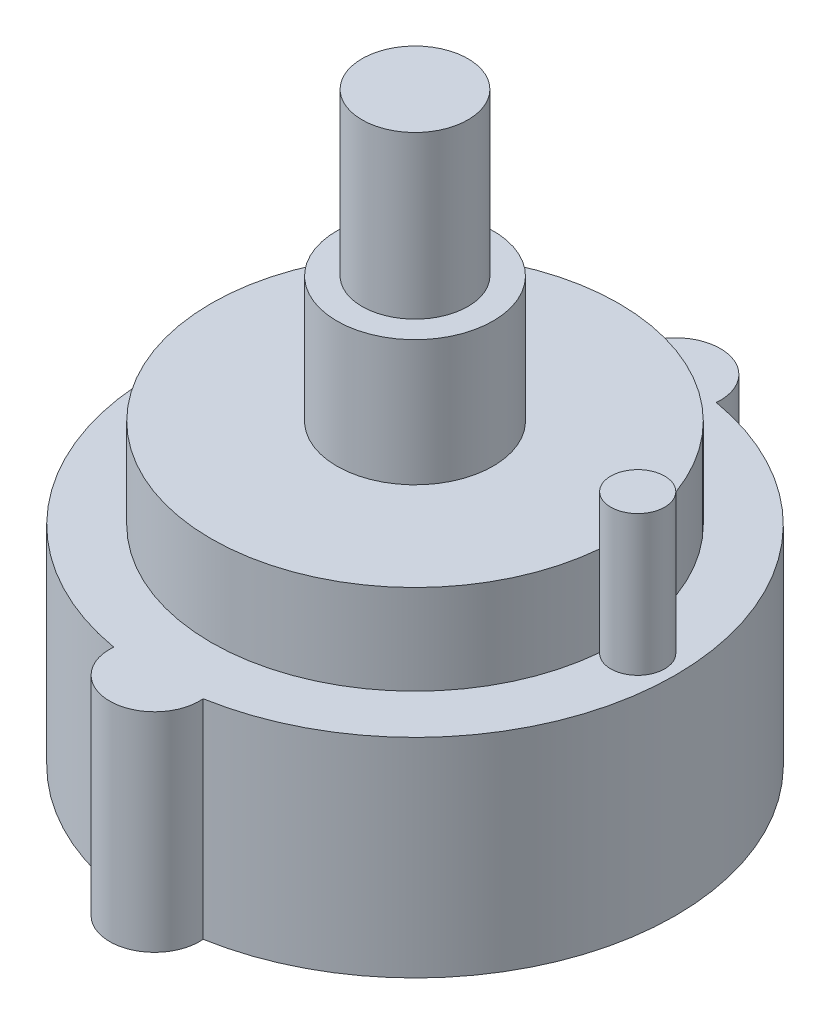
from build123d import *

# Parameters (mm, degrees)
SKETCH1_R                = 14.5
BOSS_EXTRUDE1_DEPTH      = 11.6
SKETCH2_R                = 11.35
BOSS_EXTRUDE2_DEPTH      = 5
SKETCH3_R                = 4.35
BOSS_EXTRUDE3_DEPTH      = 7
SKETCH4_R                = 2.95
BOSS_EXTRUDE4_DEPTH      = 9
SKETCH5_R                = 2.5
BOSS_EXTRUDE5_DEPTH      = 11.6
SKETCH6_R                = 1.5
BOSS_EXTRUDE6_DEPTH      = 2.8
BOSS_EXTRUDE6_DEPTH_BACK = 16.6


with BuildPart() as part:
    # Sketch1 → Boss-Extrude1 (new body)
    with BuildSketch(Plane(origin=(0, 0, 0), x_dir=(1, 0, 0), z_dir=(0, 1, 0))):
        Circle(SKETCH1_R)
    extrude(amount=BOSS_EXTRUDE1_DEPTH)

    # Sketch2 → Boss-Extrude2 (add)
    with BuildSketch(Plane(origin=(0, 11.6, 0), x_dir=(1, 0, 0), z_dir=(0, 1, 0))):
        Circle(SKETCH2_R)
    extrude(amount=BOSS_EXTRUDE2_DEPTH)

    # Sketch3 → Boss-Extrude3 (add)
    with BuildSketch(Plane(origin=(0, 16.6, 0), x_dir=(1, 0, 0), z_dir=(0, 1, 0))):
        Circle(SKETCH3_R)
    extrude(amount=BOSS_EXTRUDE3_DEPTH)

    # Sketch4 → Boss-Extrude4 (add)
    with BuildSketch(Plane(origin=(0, 23.6, 0), x_dir=(1, 0, 0), z_dir=(0, 1, 0))):
        Circle(SKETCH4_R)
    extrude(amount=BOSS_EXTRUDE4_DEPTH)

    # Sketch5 → Boss-Extrude5 (add)
    with BuildSketch(Plane.XZ):
        with Locations((0, 14.5)):
            Circle(SKETCH5_R)
        with Locations((0, -14.5)):
            Circle(SKETCH5_R)
    extrude(amount=-BOSS_EXTRUDE5_DEPTH)

    # Sketch6 → Boss-Extrude6 (add, two sides)
    with BuildSketch(Plane(origin=(0, 16.6, 0), x_dir=(1, 0, 0), z_dir=(0, 1, 0))) as boss_extrude6_sk:
        with Locations((12.4, 0)):
            Circle(SKETCH6_R)
    extrude(amount=BOSS_EXTRUDE6_DEPTH)
    extrude(boss_extrude6_sk.sketch, amount=-BOSS_EXTRUDE6_DEPTH_BACK)


solid = part.part
